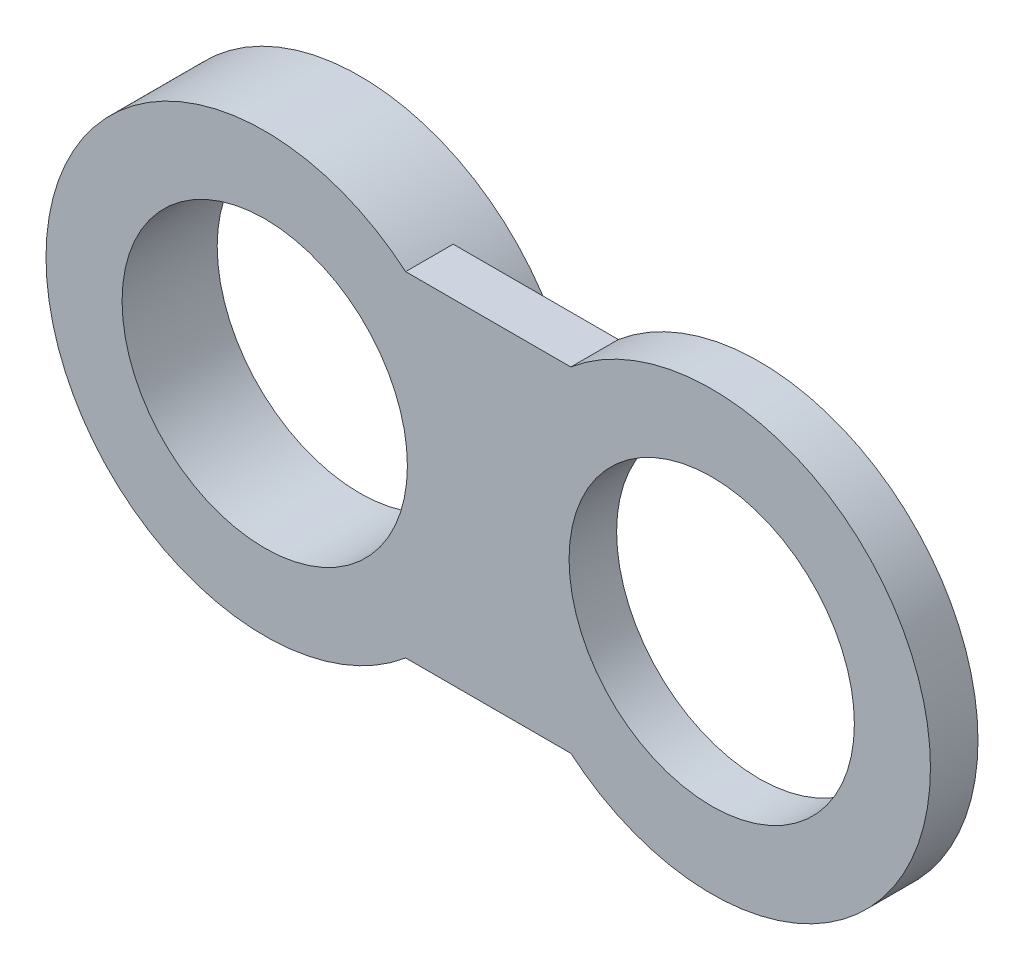
from build123d import *

# Parameters (mm, degrees)
BOSS_EXTRUDE1_DEPTH      = 25
BOSS_EXTRUDE1_DEPTH_BACK = 25
SKETCH4_R                = 150
BOSS_EXTRUDE2_START      = -75
SKETCH4_4_R              = 150
BOSS_EXTRUDE2_DEPTH      = 75


with BuildPart() as part:
    # Sketch4 → Boss-Extrude1 (new, two sides: drawn at the far end of the back side and taken through both)
    with BuildSketch(Plane.XY.offset(-BOSS_EXTRUDE1_DEPTH_BACK)):
        with BuildLine():
            Line((71.8245835, 175.909198012), (-101.8245835, 175.909198012))
            ThreePointArc((-101.8245835, 175.909198012), (-480, 0), (-101.8245835, -175.909198012))
            Line((-101.8245835, -175.909198012), (71.8245835, -175.909198012))
            ThreePointArc((71.8245835, -175.909198012), (450, 0), (71.8245835, 175.909198012))
        make_face()
        with Locations((220, 0)):
            Circle(SKETCH4_R, mode=Mode.SUBTRACT)
        with Locations((-250, 0)):
            Circle(SKETCH4_R, mode=Mode.SUBTRACT)
    extrude(amount=BOSS_EXTRUDE1_DEPTH + BOSS_EXTRUDE1_DEPTH_BACK)

    # Sketch4_4 → Boss-Extrude2 (add)
    with BuildSketch(Plane.XY.offset(BOSS_EXTRUDE2_START)):
        with BuildLine():
            ThreePointArc((-20, 0), (-41.45702386, 97.004263321), (-101.8245835, 175.909198012))
            ThreePointArc((-101.8245835, 175.909198012), (-480, 0), (-101.8245835, -175.909198012))
            ThreePointArc((-101.8245835, -175.909198012), (-41.45702386, -97.004263321), (-20, 0))
        make_face()
        with Locations((-250, 0)):
            Circle(SKETCH4_4_R, mode=Mode.SUBTRACT)
    extrude(amount=BOSS_EXTRUDE2_DEPTH)


solid = part.part
